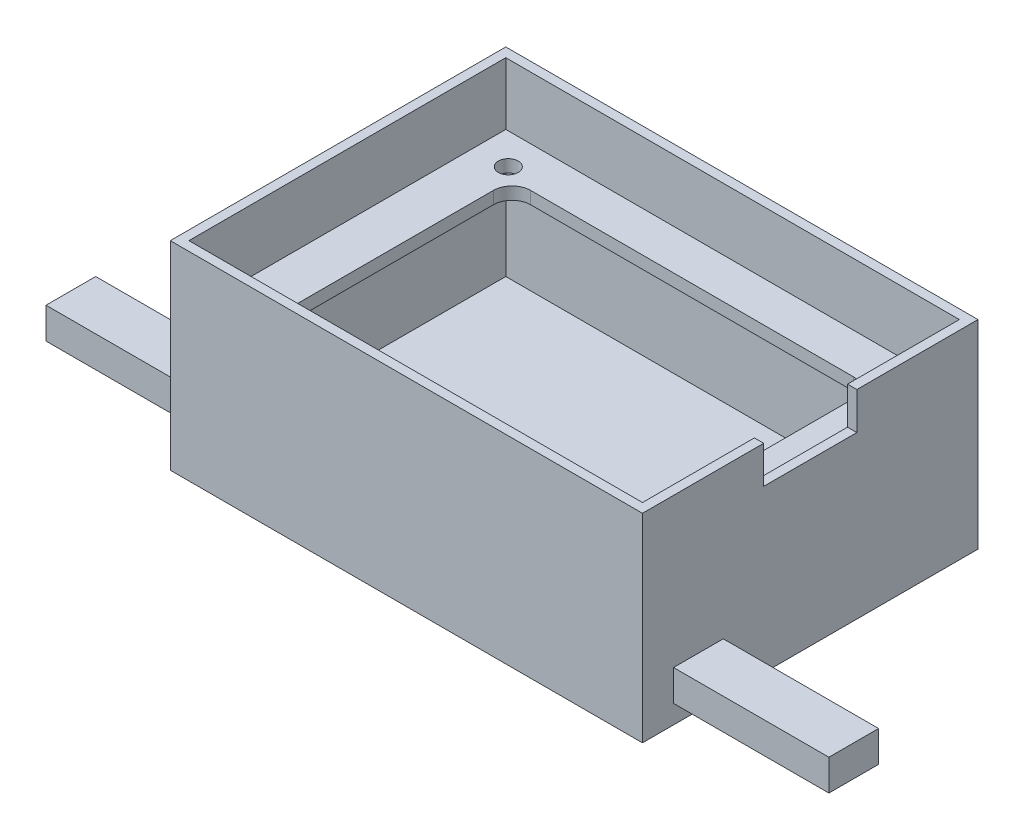
from build123d import *

# Parameters (mm, degrees)
ENCLOSURE_SHELL_SKETCH_W      = 76
ENCLOSURE_SHELL_SKETCH_H      = 54
ENCLOSURE_SHELL_FEATURE_DEPTH = 32
ENCLOSURE_GAP_SKETCH_W        = 73
ENCLOSURE_GAP_SKETCH_H        = 51
ENCLOSURE_GAP_FEATURE_DEPTH   = 30
CAMERA_CORD_HOLE_SKETCH_W     = 20
CAMERA_CORD_HOLE_SKETCH_H     = 12
CAMERA_CORD_HOLE_DEPTH        = 3
BATTERY_CUT_REACH             = 78
BATTERY_CUT_DIRECTION_2_DEPTH = 1
RIGHT_TAB_FEATURE_SKETCH_W    = 8
RIGHT_TAB_FEATURE_SKETCH_H    = 5
RIGHT_TAB_FEATURE_DEPTH       = 25
LEFT_TAB_FEATURE_SKETCH_W     = 8
LEFT_TAB_FEATURE_SKETCH_H     = 5
LEFT_TAB_FEATURE_DEPTH        = 25
SKETCH1_W                     = 76
SKETCH1_H                     = 54
BOSS_EXTRUDE1_DEPTH           = 20
CUT_EXTRUDE2_START            = -2
SKETCH5_W                     = 72
SKETCH5_H                     = 50
CUT_EXTRUDE2_DEPTH            = 18
SCREW_SHELL_SKETCH_R          = 2.5
SCREW_SHELL_FEATURE_DEPTH     = 1
SKETCH6_W                     = 58
SKETCH6_H                     = 38
CUT_EXTRUDE3_DEPTH            = 2
SCREW_HOLE_SKETCH_R           = 1.6
CUT_EXTRUDE4_DEPTH            = 2
FILLET1_R                     = 3
FILLET2_R                     = 3
FILLET3_R                     = 3
FILLET4_R                     = 3


with BuildPart() as part:
    # Enclosure Shell Sketch → Enclosure Shell Feature (new body)
    with BuildSketch(Plane(origin=(0, 0, 0), x_dir=(1, 0, 0), z_dir=(0, 1, 0))):
        Rectangle(ENCLOSURE_SHELL_SKETCH_W, ENCLOSURE_SHELL_SKETCH_H)
    extrude(amount=ENCLOSURE_SHELL_FEATURE_DEPTH)

    # Enclosure Gap Sketch → Enclosure Gap Feature (cut)
    with BuildSketch(Plane(origin=(0, 32, 0), x_dir=(1, 0, 0), z_dir=(0, 1, 0))):
        Rectangle(ENCLOSURE_GAP_SKETCH_W, ENCLOSURE_GAP_SKETCH_H)
    extrude(amount=-ENCLOSURE_GAP_FEATURE_DEPTH, mode=Mode.SUBTRACT)

    # Camera Cord Hole Sketch → Camera Cord Hole (cut, through all)
    with BuildSketch(Plane(origin=(0, 2, 0), x_dir=(1, 0, 0), z_dir=(0, 1, 0))):
        with Locations((-17.5, -9.5)):
            Rectangle(CAMERA_CORD_HOLE_SKETCH_W, CAMERA_CORD_HOLE_SKETCH_H)
    extrude(amount=-CAMERA_CORD_HOLE_DEPTH, mode=Mode.SUBTRACT)

    # Battery Cut Sketch → Battery Cut (cut, up to next)
    with BuildSketch(Plane.ZY.offset(-38), mode=Mode.PRIVATE) as battery_cut_sk1:
        Polygon((0, 32), (7.492527579, 32), (7.492527579, 26), (-7.5, 26), (-7.5, 32), align=None)
    battery_cut_tool1 = extrude(battery_cut_sk1.sketch, amount=BATTERY_CUT_REACH, mode=Mode.PRIVATE) & part.part
    add(battery_cut_tool1.solids().sort_by_distance((38, 29, -0.003736))[0], mode=Mode.SUBTRACT)

    # Battery Cut Sketch → Battery Cut direction 2 (cut)
    with BuildSketch(Plane.ZY.offset(-38)):
        Polygon((0, 32), (7.492527579, 32), (7.492527579, 26), (-7.5, 26), (-7.5, 32), align=None)
    extrude(amount=-BATTERY_CUT_DIRECTION_2_DEPTH, mode=Mode.SUBTRACT)

    # Right Tab Feature Sketch → Right Tab Feature (add)
    with BuildSketch(Plane(origin=(38, 0, 0), x_dir=(0, 0, -1), z_dir=(1, 0, 0))):
        with Locations((-18, 5.5)):
            Rectangle(RIGHT_TAB_FEATURE_SKETCH_W, RIGHT_TAB_FEATURE_SKETCH_H)
    extrude(amount=RIGHT_TAB_FEATURE_DEPTH)

    # Left Tab Feature Sketch → Left Tab Feature (add)
    with BuildSketch(Plane.ZY.offset(38)):
        with Locations((18, 5.5)):
            Rectangle(LEFT_TAB_FEATURE_SKETCH_W, LEFT_TAB_FEATURE_SKETCH_H)
    extrude(amount=LEFT_TAB_FEATURE_DEPTH)

    # Sketch1 → Boss-Extrude1 (add)
    with BuildSketch(Plane(origin=(0, 2, 0), x_dir=(1, 0, 0), z_dir=(0, 1, 0))):
        Rectangle(SKETCH1_W, SKETCH1_H)
    extrude(amount=BOSS_EXTRUDE1_DEPTH)

    # Sketch5 → Cut-Extrude2 (cut)
    with BuildSketch(Plane(origin=(0, 0, 0), x_dir=(-1, 0, 0), z_dir=(0, -1, 0)).offset(CUT_EXTRUDE2_START)):
        Rectangle(SKETCH5_W, SKETCH5_H)
    extrude(amount=-CUT_EXTRUDE2_DEPTH, mode=Mode.SUBTRACT)

    # Screw Shell Sketch → Screw Shell Feature (add)
    with BuildSketch(Plane(origin=(0, 22, 0), x_dir=(1, 0, 0), z_dir=(0, 1, 0))):
        with Locations((-30.088214765, 20.515946978)):
            Circle(SCREW_SHELL_SKETCH_R)
        with Locations((-32.1, -21.5)):
            Circle(SCREW_SHELL_SKETCH_R)
        with Locations((32.1, 21.5)):
            Circle(SCREW_SHELL_SKETCH_R)
        with Locations((30.088214765, -20.515946978)):
            Circle(SCREW_SHELL_SKETCH_R)
    extrude(amount=-SCREW_SHELL_FEATURE_DEPTH)

    # Sketch6 → Cut-Extrude3 (cut)
    with BuildSketch(Plane(origin=(0, 22, 0), x_dir=(1, 0, 0), z_dir=(0, 1, 0))):
        Rectangle(SKETCH6_W, SKETCH6_H)
    extrude(amount=-CUT_EXTRUDE3_DEPTH, mode=Mode.SUBTRACT)

    # Screw Hole Sketch → Cut-Extrude4 (cut)
    with BuildSketch(Plane(origin=(0, 22, 0), x_dir=(1, 0, 0), z_dir=(0, 1, 0))):
        with Locations((-31.096, 20.5)):
            Circle(SCREW_HOLE_SKETCH_R)
        with Locations((-31.1, -20.5)):
            Circle(SCREW_HOLE_SKETCH_R)
        with Locations((31.096, -20.5)):
            Circle(SCREW_HOLE_SKETCH_R)
        with Locations((31.1, 20.5)):
            Circle(SCREW_HOLE_SKETCH_R)
    extrude(amount=-CUT_EXTRUDE4_DEPTH, mode=Mode.SUBTRACT)

    # Fillet1
    fillet1_edges = [part.edges().sort_by_distance(p)[0] for p in [
        (-29, 21, -19),
    ]]
    fillet(fillet1_edges, radius=FILLET1_R)

    # Fillet2
    fillet2_edges = [part.edges().sort_by_distance(p)[0] for p in [
        (29, 21, -19),
    ]]
    fillet(fillet2_edges, radius=FILLET2_R)

    # Fillet3
    fillet3_edges = [part.edges().sort_by_distance(p)[0] for p in [
        (29, 21, 19),
    ]]
    fillet(fillet3_edges, radius=FILLET3_R)

    # Fillet4
    fillet4_edges = [part.edges().sort_by_distance(p)[0] for p in [
        (-29, 21, 19),
    ]]
    fillet(fillet4_edges, radius=FILLET4_R)


solid = part.part
